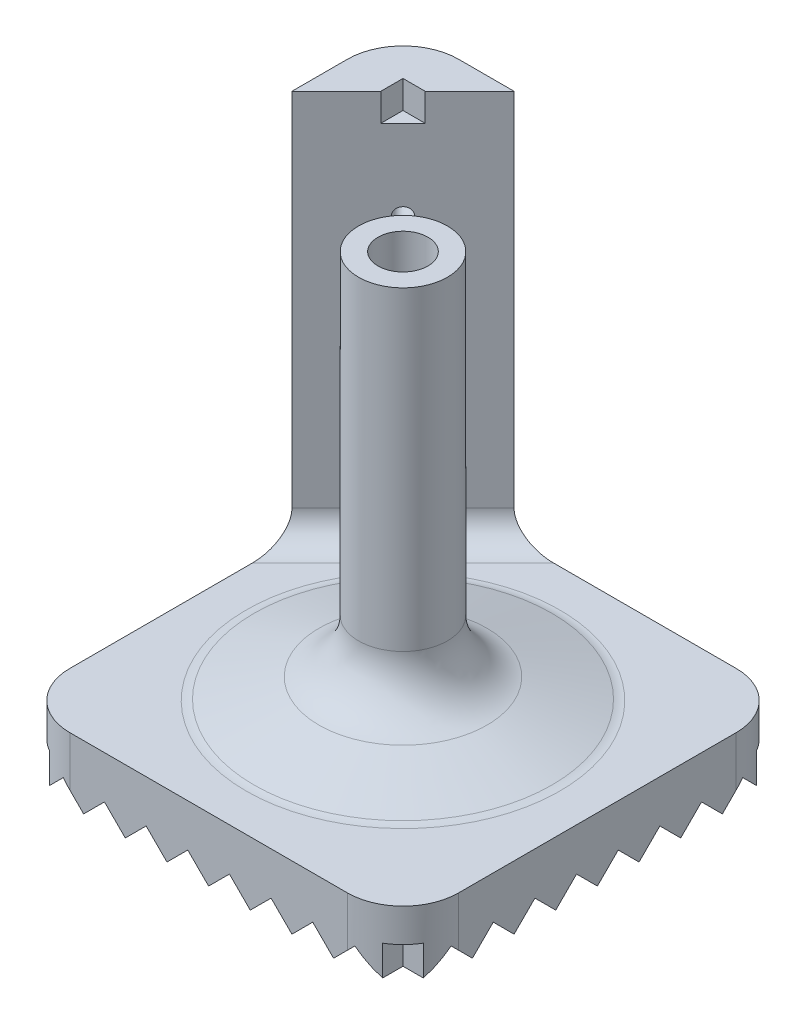
from build123d import *

# Parameters (mm, degrees)
SKETCH_1_W                = 70
SKETCH_1_H                = 70
EXTRUDE_1_DEPTH           = 6
SKETCH_2_R                = 8
EXTRUDE_2_DEPTH           = 70
SKETCH_3_R                = 4.5
CUT_EXTRUDE_3_DEPTH       = 77
EXTRUDE_3_DEPTH           = 70
FILLET_1_R                = 10
SKETCH_5_R                = 2.5
SKETCH_5_R_2              = 1.5
CUT_EXTRUDE_5_DEPTH       = 15.142136
CUT_EXTRUDE_6_DEPTH       = 5
EXTRUDE_4_DEPTH           = 70
EXTRUDE_5_DEPTH           = 70
CUT_EXTRUDE_7_DEPTH       = 70
CUT_EXTRUDE_8_DEPTH       = 70
CUT_EXTRUDE_9_DEPTH       = 16
SKETCH_13_R               = 4.5
CUT_EXTRUDE_10_DEPTH      = 1
CUT_EXTRUDE_10_DEPTH_BACK = 82.437028
FILLET_2_R                = 10
FILLET_3_R                = 5
FILLET_5_R                = 5


with BuildPart() as part:
    # 草图1 → 凸台-拉伸1 (new body)
    with BuildSketch(Plane(origin=(0, 0, 0), x_dir=(1, 0, 0), z_dir=(0, 1, 0))):
        Rectangle(SKETCH_1_W, SKETCH_1_H)
    extrude(amount=EXTRUDE_1_DEPTH)

    # 草图2 → 凸台-拉伸2 (add)
    with BuildSketch(Plane(origin=(0, 6, 0), x_dir=(1, 0, 0), z_dir=(0, 1, 0))):
        Circle(SKETCH_2_R)
    extrude(amount=EXTRUDE_2_DEPTH)

    # 草图3 → 切除-拉伸3 (cut, through all)
    with BuildSketch(Plane(origin=(0, 0, 0), x_dir=(1, 0, 0), z_dir=(0, 1, 0))):
        Circle(SKETCH_3_R)
    extrude(amount=CUT_EXTRUDE_3_DEPTH, mode=Mode.SUBTRACT)

    # 草图4 → 凸台-拉伸3 (add)
    with BuildSketch(Plane(origin=(0, 6, 0), x_dir=(1, 0, 0), z_dir=(0, 1, 0))):
        Polygon((-35, 35), (-15, 35), (-35, 15), align=None)
    extrude(amount=EXTRUDE_3_DEPTH)

    # 圆角1
    fillet_1_edges = [part.edges().sort_by_distance(p)[0] for p in [
        (35, 3, 35),
        (-35, 3, 35),
        (-35, 38, -35),
        (35, 3, -35),
    ]]
    fillet(fillet_1_edges, radius=FILLET_1_R)

    # 草图5 → 切除-拉伸5 (cut, through all)
    with BuildSketch(Plane(origin=(-25, 0, -25), x_dir=(0.707107, 0, -0.707107), z_dir=(0.707107, 0, 0.707107))):
        with Locations((0, 45)):
            Circle(SKETCH_5_R)
        with Locations((0, 56.502966)):
            Circle(SKETCH_5_R_2)
    extrude(amount=-CUT_EXTRUDE_5_DEPTH, mode=Mode.SUBTRACT)

    # 草图7 → 切除-拉伸6 (cut)
    with BuildSketch(Plane(origin=(0, 76, 0), x_dir=(1, 0, 0), z_dir=(0, 1, 0))):
        Polygon((-23, 27), (-27, 27), (-27, 23), align=None)
    extrude(amount=-CUT_EXTRUDE_6_DEPTH, mode=Mode.SUBTRACT)

    # 草图8 → 凸台-拉伸4 (add)
    with BuildSketch(Plane(origin=(0, 0, -35), x_dir=(-1, 0, 0), z_dir=(0, 0, -1))):
        Polygon((-22.5, -5.437028), (-18.75, -1.687028), (-15, -5.437028), (-11.25, -1.687028), (-7.5, -5.437028), (-3.75, -1.687028), (0, -5.437028), (3.75, -1.687028), (7.5, -5.437028), (11.25, -1.687028), (15, -5.437028), (18.75, -1.687028), (22.5, -5.437028), (26.25, -1.687028), (30, -5.437028), (30, 0), (-30, 0), (-30, -5.437028), (-26.25, -1.687028), align=None)
    extrude(amount=-EXTRUDE_4_DEPTH)

    # 草图9 → 凸台-拉伸5 (add)
    with BuildSketch(Plane.ZY.offset(35)):
        Polygon((-22.5, -5.437028), (-18.75, -1.687028), (-15, -5.437028), (-11.25, -1.687028), (-7.5, -5.437028), (-3.75, -1.687028), (0, -5.437028), (3.75, -1.687028), (7.5, -5.437028), (11.25, -1.687028), (15, -5.437028), (18.75, -1.687028), (22.5, -5.437028), (26.25, -1.687028), (30, -5.437028), (30, 0), (-30, 0), (-30, -5.437028), (-26.25, -1.687028), align=None)
    extrude(amount=-EXTRUDE_5_DEPTH)

    # 草图10 → 切除-拉伸7 (cut)
    with BuildSketch(Plane.ZY.offset(35)):
        Polygon((-30, -5.437028), (-22.5, -5.437028), (-26.25, -1.687028), align=None)
        Polygon((-18.75, -1.687028), (-22.5, -5.437028), (-15, -5.437028), align=None)
        Polygon((-11.25, -1.687028), (-15, -5.437028), (-7.5, -5.437028), align=None)
        Polygon((-3.75, -1.687028), (-7.5, -5.437028), (0, -5.437028), align=None)
        Polygon((3.75, -1.687028), (0, -5.437028), (7.5, -5.437028), align=None)
        Polygon((11.25, -1.687028), (7.5, -5.437028), (15, -5.437028), align=None)
        Polygon((18.75, -1.687028), (15, -5.437028), (22.5, -5.437028), align=None)
        Polygon((26.25, -1.687028), (22.5, -5.437028), (30, -5.437028), align=None)
    extrude(amount=-CUT_EXTRUDE_7_DEPTH, mode=Mode.SUBTRACT)

    # 草图11 → 切除-拉伸8 (cut)
    with BuildSketch(Plane.XY.offset(35)):
        Polygon((26.25, -1.687028), (22.5, -5.437028), (30, -5.437028), align=None)
        Polygon((18.75, -1.687028), (15, -5.437028), (22.5, -5.437028), align=None)
        Polygon((11.25, -1.687028), (7.5, -5.437028), (15, -5.437028), align=None)
        Polygon((3.75, -1.687028), (0, -5.437028), (7.5, -5.437028), align=None)
        Polygon((-3.75, -1.687028), (-7.5, -5.437028), (0, -5.437028), align=None)
        Polygon((-11.25, -1.687028), (-15, -5.437028), (-7.5, -5.437028), align=None)
        Polygon((-18.75, -1.687028), (-22.5, -5.437028), (-15, -5.437028), align=None)
        Polygon((-30, -5.437028), (-22.5, -5.437028), (-26.25, -1.687028), align=None)
    extrude(amount=-CUT_EXTRUDE_8_DEPTH, mode=Mode.SUBTRACT)

    # 草图12 → 切除-拉伸9 (cut)
    with BuildSketch(Plane(origin=(0, 6, 0), x_dir=(1, 0, 0), z_dir=(0, 1, 0))):
        with BuildLine():
            ThreePointArc((-25, 35), (-32.071068, 32.071068), (-35, 25))
            Line((-35, 25), (-35, 35))
            Line((-35, 35), (-25, 35))
        make_face()
        with BuildLine():
            Line((35, 35), (35, 25))
            ThreePointArc((35, 25), (32.071068, 32.071068), (25, 35))
            Line((25, 35), (35, 35))
        make_face()
        with BuildLine():
            Line((35, -35), (25, -35))
            ThreePointArc((25, -35), (32.071068, -32.071068), (35, -25))
            Line((35, -25), (35, -35))
        make_face()
        with BuildLine():
            Line((-35, -35), (-35, -25))
            ThreePointArc((-35, -25), (-32.071068, -32.071068), (-25, -35))
            Line((-25, -35), (-35, -35))
        make_face()
    extrude(amount=-CUT_EXTRUDE_9_DEPTH, mode=Mode.SUBTRACT)

    # 草图13 → 切除-拉伸10 (cut, two sides)
    with BuildSketch(Plane(origin=(0, 76, 0), x_dir=(1, 0, 0), z_dir=(0, 1, 0))) as cut_extrude_10_sk:
        Circle(SKETCH_13_R)
    extrude(amount=CUT_EXTRUDE_10_DEPTH, mode=Mode.SUBTRACT)
    extrude(cut_extrude_10_sk.sketch, amount=-CUT_EXTRUDE_10_DEPTH_BACK, mode=Mode.SUBTRACT)

    # 草图17 → 旋转1 (revolve)
    with BuildSketch(Plane(origin=(0, 0, 0), x_dir=(0.707107, 0, 0.707107), z_dir=(-0.707107, 0, 0.707107))):
        Polygon((8, 11.856155), (27.50497, 6), (8, 6), align=None)
    revolve(axis=Axis((0, 339.956617, 0), (0, -1, 0)))

    # 圆角2
    fillet_2_edges = [part.edges().sort_by_distance(p)[0] for p in [
        (-7.391036, 11.856155, -3.061467),
    ]]
    fillet(fillet_2_edges, radius=FILLET_2_R)

    # 圆角3
    fillet_3_edges = [part.edges().sort_by_distance(p)[0] for p in [
        (-19.448951, 6, -19.448951),
    ]]
    fillet(fillet_3_edges, radius=FILLET_3_R)

    # 圆角5
    fillet_5_edges = [part.edges().sort_by_distance(p)[0] for p in [
        (-25, 6, -25),
    ]]
    fillet(fillet_5_edges, radius=FILLET_5_R)


solid = part.part
